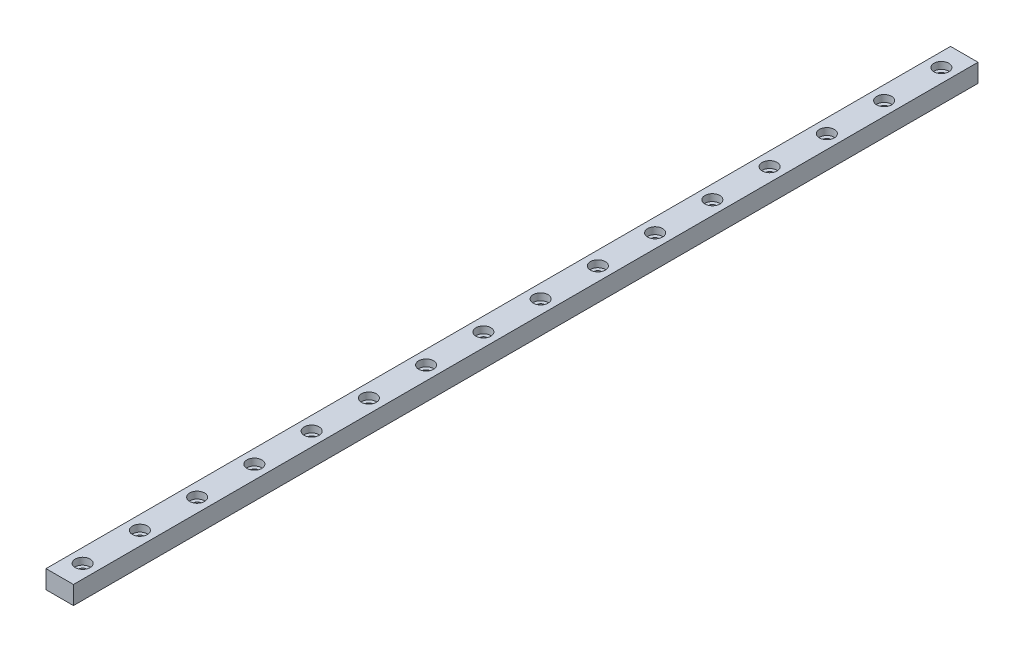
from build123d import *

# Parameters (mm, degrees)
SKETCH1_W                      = 12
SKETCH1_H                      = 8
BOSS_EXTRUDE1_DEPTH            = 395
CBORE_FOR_M3_SHCS1_D           = 3.4
CBORE_FOR_M3_SHCS1_CBORE_D     = 6.5
CBORE_FOR_M3_SHCS1_CBORE_DEPTH = 3


with BuildPart() as part:
    # Sketch1 → Boss-Extrude1 (new body)
    with BuildSketch(Plane.XY):
        with Locations((6, 4)):
            Rectangle(SKETCH1_W, SKETCH1_H)
    extrude(amount=BOSS_EXTRUDE1_DEPTH)

    # CBORE for M3 SHCS1 (through all)
    with Locations(Plane(origin=(0, 8, 0), x_dir=(1, 0, 0), z_dir=(0, 1, 0))):
        with Locations((6, -385), (6, -360), (6, -335), (6, -310), (6, -285), (6, -260), (6, -235), (6, -210), (6, -185), (6, -160), (6, -135), (6, -110), (6, -85), (6, -60), (6, -35), (6, -10)):
            CounterBoreHole(CBORE_FOR_M3_SHCS1_D / 2, CBORE_FOR_M3_SHCS1_CBORE_D / 2, CBORE_FOR_M3_SHCS1_CBORE_DEPTH)


solid = part.part
